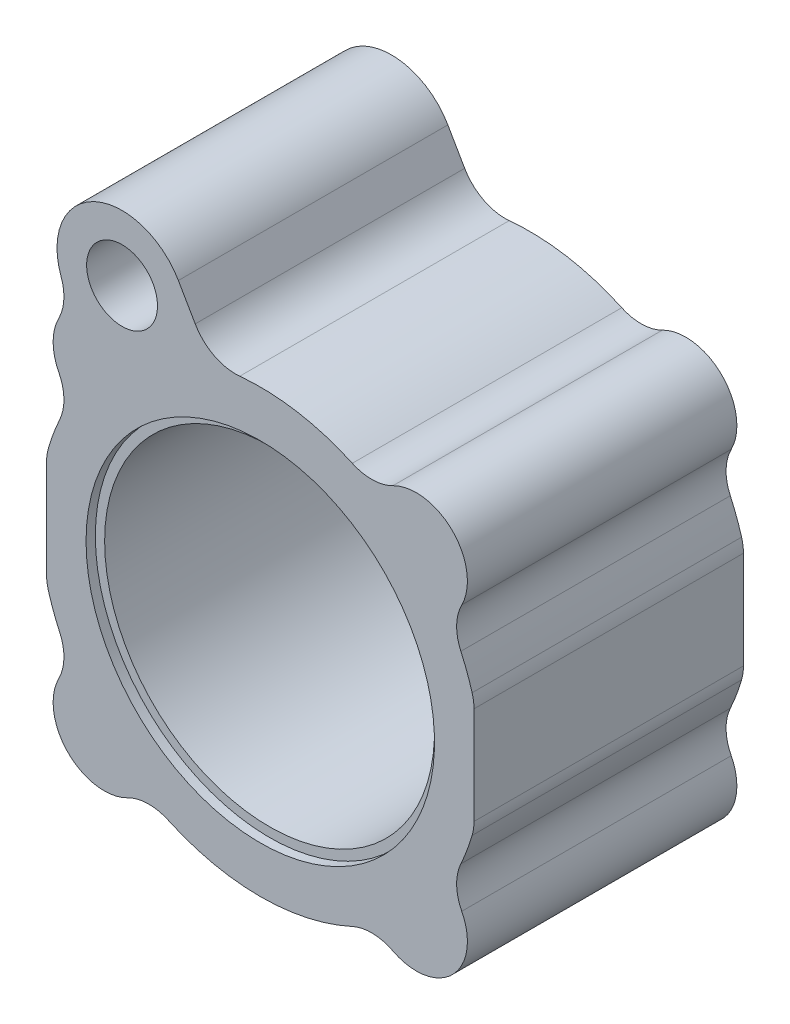
from build123d import *

# Parameters (mm, degrees)
SKETCH1_R              = 31.5
BASE_EXTRUDE_DEPTH     = 60
F_4_STK_M14_D          = 12
F_4_STK_M14_DEPTH      = 28
F_4_STK_M14_TIP        = 3.605163714
F_3_8_RG_OLIEHUL_D     = 15.25
F_3_8_RG_OLIEHUL_DEPTH = 27
F_3_8_RG_OLIEHUL_TIP   = 4.58156222


with BuildPart() as part:
    # Sketch1 → Base-Extrude (new body)
    with BuildSketch(Plane.XY):
        with BuildLine():
            Line((46, 10.5), (46, -10.5))
            ThreePointArc((46, -10.5), (45.899494937, -11.914213562), (45.6, -13.3))
            ThreePointArc((45.6, -13.3), (44.505223817, -16.599248568), (43.172095387, -19.809598175))
            ThreePointArc((43.172095387, -19.809598175), (42.263487891, -24.204984204), (43.368869256, -28.555055234))
            ThreePointArc((43.368869256, -28.555055234), (41.365746699, -41.365746699), (28.555055234, -43.368869256))
            ThreePointArc((28.555055234, -43.368869256), (24.204984204, -42.263487891), (19.809598175, -43.172095387))
            ThreePointArc((19.809598175, -43.172095387), (0, -47.5), (-19.809598175, -43.172095387))
            ThreePointArc((-19.809598175, -43.172095387), (-24.204984204, -42.263487891), (-28.555055234, -43.368869256))
            ThreePointArc((-28.555055234, -43.368869256), (-41.365746699, -41.365746699), (-43.368869256, -28.555055234))
            ThreePointArc((-43.368869256, -28.555055234), (-42.263487891, -24.204984204), (-43.172095387, -19.809598175))
            ThreePointArc((-43.172095387, -19.809598175), (-44.505223817, -16.599248568), (-45.6, -13.3))
            ThreePointArc((-45.6, -13.3), (-45.899494937, -11.914213562), (-46, -10.5))
            Line((-46, -10.5), (-46, 10.5))
            ThreePointArc((-46, 10.5), (-45.899494937, 11.914213562), (-45.6, 13.3))
            ThreePointArc((-45.6, 13.3), (-44.505223817, 16.599248568), (-43.172095387, 19.809598175))
            ThreePointArc((-43.172095387, 19.809598175), (-42.263487891, 24.204984204), (-43.368869256, 28.555055234))
            ThreePointArc((-43.368869256, 28.555055234), (-44.587572018, 33.588968915), (-43.367590856, 38.622572926))
            ThreePointArc((-43.367590856, 38.622572926), (-42.276823958, 42.595028926), (-42.879968246, 46.670123534))
            ThreePointArc((-42.879968246, 46.670123534), (-35.700475242, 64.200995275), (-17.625644347, 58.528511525))
            Line((-17.625644347, 58.528511525), (-14.001541461, 52.251381194))
            ThreePointArc((-14.001541461, 52.251381194), (-9.933210275, 48.36801221), (-4.412367871, 47.294619248))
            ThreePointArc((-4.412367871, 47.294619248), (-2.208572587, 47.448627031), (0, 47.5))
            ThreePointArc((0, 47.5), (10.138428604, 46.405412028), (19.809598175, 43.172095387))
            ThreePointArc((19.809598175, 43.172095387), (24.204984204, 42.263487891), (28.555055234, 43.368869256))
            ThreePointArc((28.555055234, 43.368869256), (41.365746699, 41.365746699), (43.368869256, 28.555055234))
            ThreePointArc((43.368869256, 28.555055234), (42.263487891, 24.204984204), (43.172095387, 19.809598175))
            ThreePointArc((43.172095387, 19.809598175), (44.505223817, 16.599248568), (45.6, 13.3))
            ThreePointArc((45.6, 13.3), (45.899494937, 11.914213562), (46, 10.5))
        make_face()
        Circle(SKETCH1_R, mode=Mode.SUBTRACT)
    extrude(amount=BASE_EXTRUDE_DEPTH)

    # Sketch2 → Indv uddrejning (revolve, cut)
    with BuildSketch(Plane(origin=(0, 0, 0), x_dir=(0, 0, -1), z_dir=(1, 0, 0))):
        Polygon((0, 90), (0, 0), (-2.72299253, 0), (-60, 0), (-60, 90), (-59, 90), (-59, 37.5), (-57, 37.5), (-57, 35.5), (-2.732050808, 35.5), (-1, 36.5), (-1, 90), align=None)
    revolve(axis=Axis((0, 0, 0), (0, 0, 1)), mode=Mode.SUBTRACT)

    # 4 stk M14
    with Locations(Plane(origin=(0, 0, 1), x_dir=(-1, 0, 0), z_dir=(0, 0, -1))):
        with Locations((-33.587572106, 33.587572106), (33.587572106, 33.587572106), (-33.587572106, -33.587572106), (33.587572106, -33.587572106)):
            Hole(F_4_STK_M14_D / 2, depth=F_4_STK_M14_DEPTH)
            with Locations((0, 0, -(F_4_STK_M14_DEPTH + F_4_STK_M14_TIP / 2))):  # 118° drill point
                Cone(0, F_4_STK_M14_D / 2, F_4_STK_M14_TIP, mode=Mode.SUBTRACT)

    # 3/8" RG oliehul
    with Locations(Plane.XY.offset(59)):
        with Locations((-29.75, 51.528511525)):
            Hole(F_3_8_RG_OLIEHUL_D / 2, depth=F_3_8_RG_OLIEHUL_DEPTH)
            with Locations((0, 0, -(F_3_8_RG_OLIEHUL_DEPTH + F_3_8_RG_OLIEHUL_TIP / 2))):  # 118° drill point
                Cone(0, F_3_8_RG_OLIEHUL_D / 2, F_3_8_RG_OLIEHUL_TIP, mode=Mode.SUBTRACT)

    # Sketch11 → ø12 olietilførsel (revolve, cut)
    with BuildSketch(Plane(origin=(0, 0, 0), x_dir=(0, 0, -1), z_dir=(0.866025404, 0.5, 0))):
        Polygon((-34.808616204, 59.5), (-30.894377504, 53.696902482), (-81.608568913, -55.060031963), (-87.046415635, -52.524322392), align=None)
    revolve(axis=Axis((-29.75, 51.528511525, 34.808616204), (0.453153894, -0.784885567, 0.422618262)), mode=Mode.SUBTRACT)


solid = part.part
